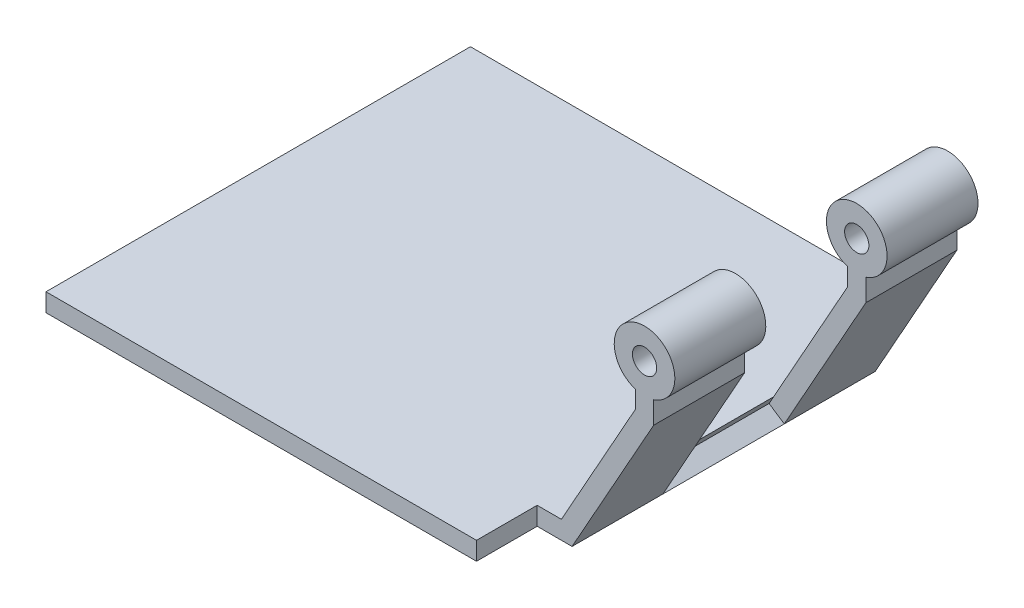
from build123d import *

# Parameters (mm, degrees)
SKETCH1_R               = 5
BOSS_EXTRUDE1_DEPTH     = 50
SKETCH2_R               = 2
CUT_EXTRUDE1_DEPTH      = 51
SKETCH7_W               = 20
SKETCH7_H               = 39.987182744
CUT_EXTRUDE3_DEPTH      = 10
CUT_EXTRUDE3_DEPTH_BACK = 10
BOSS_EXTRUDE2_REACH     = 52
CUT_EXTRUDE4_REACH      = 100.711
SKETCH9_W               = 20
SKETCH9_H               = 10.896319728
CUT_EXTRUDE6_REACH      = 52
SKETCH11_W              = 5
SKETCH11_H              = 3
SKETCH12_W              = 71
SKETCH12_H              = 70
BOSS_EXTRUDE3_DEPTH     = 3


with BuildPart() as part:
    # Sketch1 → Boss-Extrude1 (new body)
    with BuildSketch(Plane.XY):
        with Locations((93.71075113, 32.460861794)):
            Circle(SKETCH1_R)
        Polygon((0, 3), (0, 0), (81.758772051, 0), (95.21075113, 24.032587983), (95.21075113, 29.815076366), (92.21075113, 29.815076366), (92.21075113, 24.815076366), (80, 3), align=None)
    extrude(amount=BOSS_EXTRUDE1_DEPTH)

    # Sketch2 → Cut-Extrude1 (cut, through all)
    with BuildSketch(Plane.XY):
        with Locations((93.71075113, 32.460861794)):
            Circle(SKETCH2_R)
    extrude(amount=CUT_EXTRUDE1_DEPTH, mode=Mode.SUBTRACT)

    # Sketch7 → Cut-Extrude3 (cut, two sides)
    with BuildSketch(Plane(origin=(62.254079791, -34.846042362, 0), x_dir=(0, 0, -1), z_dir=(0.872603055, -0.488430045, 0))) as cut_extrude3_sk:
        with Locations((-25, 59.927032101)):
            Rectangle(SKETCH7_W, SKETCH7_H)
    extrude(amount=CUT_EXTRUDE3_DEPTH, mode=Mode.SUBTRACT)
    extrude(cut_extrude3_sk.sketch, amount=-CUT_EXTRUDE3_DEPTH_BACK, mode=Mode.SUBTRACT)

    # Sketch8 → Boss-Extrude2 (add, up to next)
    with BuildSketch(Plane.XY, mode=Mode.PRIVATE) as boss_extrude2_sk1:
        Polygon((66.951015515, 3), (66.951015515, 0), (81.758772051, 0), (79.25400484, 1.667244856), (80, 3), align=None)
    boss_extrude2_tool1 = extrude(boss_extrude2_sk1.sketch, amount=BOSS_EXTRUDE2_REACH, mode=Mode.PRIVATE) - part.part
    add(boss_extrude2_tool1.solids().sort_by_distance((73.552437, 1.463367, 0))[0])

    # Sketch9 → Cut-Extrude4 (cut, up to next)
    with BuildSketch(Plane(origin=(0, 0, 0), x_dir=(0, 0, -1), z_dir=(1, 0, 0)), mode=Mode.PRIVATE) as cut_extrude4_sk1:
        with Locations((-25, 32.01270193)):
            Rectangle(SKETCH9_W, SKETCH9_H)
    cut_extrude4_tool1 = extrude(cut_extrude4_sk1.sketch, amount=CUT_EXTRUDE4_REACH, mode=Mode.PRIVATE) & part.part
    add(cut_extrude4_tool1.solids().sort_by_distance((0, 32.012702, 25))[0], mode=Mode.SUBTRACT)

    # Sketch11 → Cut-Extrude6 (cut, up to next)
    with BuildSketch(Plane.XY.offset(50), mode=Mode.PRIVATE) as cut_extrude6_sk1:
        with Locations((2.5, 1.5)):
            Rectangle(SKETCH11_W, SKETCH11_H)
    cut_extrude6_tool1 = extrude(cut_extrude6_sk1.sketch, amount=-CUT_EXTRUDE6_REACH, mode=Mode.PRIVATE) & part.part
    add(cut_extrude6_tool1.solids().sort_by_distance((2.5, 1.5, 50))[0], mode=Mode.SUBTRACT)

    # Sketch12 → Boss-Extrude3 (add, through all)
    with BuildSketch(Plane(origin=(0, 3, 0), x_dir=(1, 0, 0), z_dir=(0, 1, 0))):
        with Locations((40.5, -25)):
            Rectangle(SKETCH12_W, SKETCH12_H)
    extrude(amount=-BOSS_EXTRUDE3_DEPTH)


solid = part.part
